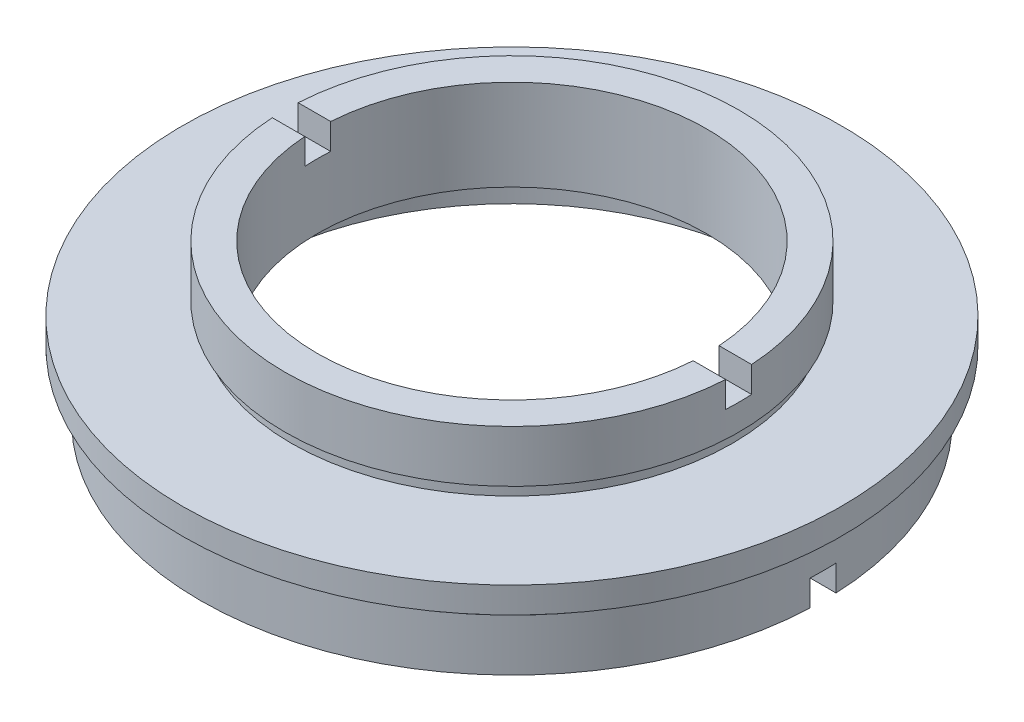
from build123d import *

# Parameters (mm, degrees)
SKETCH_2_W          = 2
SKETCH_2_H          = 3.593987872
SKETCH_2_H_2        = 6.667892238
CUT_EXTRUDE_1_DEPTH = 39.5


with BuildPart() as part:
    # 草图1 → 旋转1 (revolve)
    with BuildSketch(Plane.XY, mode=Mode.PRIVATE) as revolve_1_sk:
        Polygon((-15, 12), (-17.5, 12), (-17.5, 8), (-17, 8), (-17, 7), (-25.4, 7), (-25.4, 5), (-23.5, 5), (-23.5, 4), (-24, 4), (-24, 0), (-20.5, 0), (-20.5, 4), (-21.1, 4), (-21.1, 5), (-15, 5), align=None)
    revolve(revolve_1_sk.sketch.rotate(Axis((0, 22.677499451, 0), (0, -1, 0)), 270), axis=Axis((0, 22.677499451, 0), (0, -1, 0)))  # turned: the seam where the file's is

    # 草图2 → 切除-拉伸1 (cut, symmetric)
    with BuildSketch(Plane(origin=(0, 0, 0), x_dir=(0, 0, -1), z_dir=(1, 0, 0))):
        with Locations((0, 11.796993936)):
            Rectangle(SKETCH_2_W, SKETCH_2_H)
        with Locations((0, -1.333946119)):
            Rectangle(SKETCH_2_W, SKETCH_2_H_2)
    extrude(amount=CUT_EXTRUDE_1_DEPTH, both=True, mode=Mode.SUBTRACT)


solid = part.part
